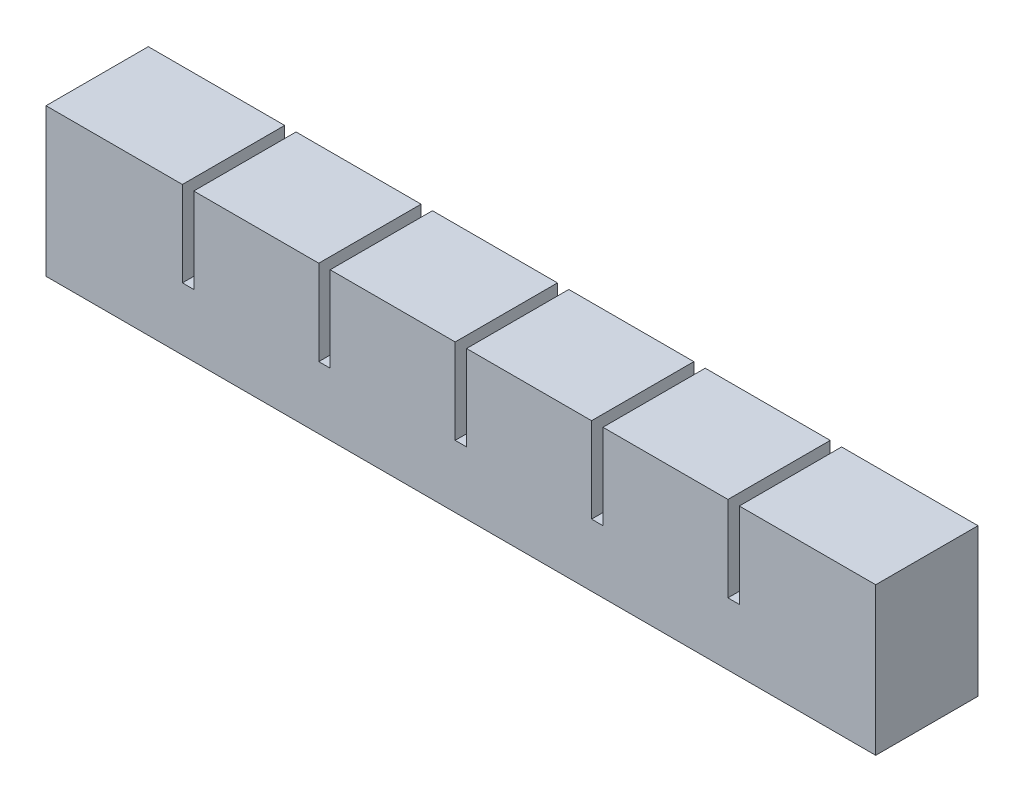
from build123d import *

# Parameters (mm, degrees)
SKETCH1_W           = 22
SKETCH1_H           = 20
BOSS_EXTRUDE1_DEPTH = 18
SKETCH2_W           = 12
SKETCH2_H           = 8
CUT_EXTRUDE1_DEPTH  = 15
SKETCH3_W           = 18
SKETCH3_H           = 5
BOSS_EXTRUDE2_DEPTH = 2
LPATTERN1_COUNT     = 6
LPATTERN1_PITCH     = 24
SKETCH4_W           = 18
SKETCH4_H           = 15
BOSS_EXTRUDE3_DEPTH = 2
SKETCH5_W           = 18
SKETCH5_H           = 20
BOSS_EXTRUDE4_DEPTH = 2
SKETCH6_W           = 132
SKETCH6_H           = 2
CUT_EXTRUDE2_DEPTH  = 2
SKETCH7_W           = 146
SKETCH7_H           = 18
BOSS_EXTRUDE5_DEPTH = 6


with BuildPart() as part:
    # Sketch1 → Boss-Extrude1 (new body)
    with BuildSketch(Plane.XY):
        with Locations((11, 10)):
            Rectangle(SKETCH1_W, SKETCH1_H)
    extrude(amount=BOSS_EXTRUDE1_DEPTH)

    # Sketch2 → Cut-Extrude1 (cut)
    with BuildSketch(Plane.XZ):
        with Locations((11, 9)):
            Rectangle(SKETCH2_W, SKETCH2_H)
    extrude(amount=-CUT_EXTRUDE1_DEPTH, mode=Mode.SUBTRACT)

    # Sketch3 → Boss-Extrude2 (add)
    with BuildSketch(Plane(origin=(22, 0, 0), x_dir=(0, 0, -1), z_dir=(1, 0, 0))):
        with Locations((-9, 2.5)):
            Rectangle(SKETCH3_W, SKETCH3_H)
    extrude(amount=BOSS_EXTRUDE2_DEPTH)


with BuildPart() as lpattern1_1:
    # LPattern1: pattern copy
    add(part.part.moved(Location(Vector(1, 0, 0) * (1 * LPATTERN1_PITCH))))


with BuildPart() as lpattern1_2:
    # LPattern1: pattern copy
    add(part.part.moved(Location(Vector(1, 0, 0) * (2 * LPATTERN1_PITCH))))


with BuildPart() as lpattern1_3:
    # LPattern1: pattern copy
    add(part.part.moved(Location(Vector(1, 0, 0) * (3 * LPATTERN1_PITCH))))


with BuildPart() as lpattern1_4:
    # LPattern1: pattern copy
    add(part.part.moved(Location(Vector(1, 0, 0) * (4 * LPATTERN1_PITCH))))


with BuildPart() as lpattern1_5:
    # LPattern1: pattern copy
    add(part.part.moved(Location(Vector(1, 0, 0) * (5 * LPATTERN1_PITCH))))


with BuildPart() as lpattern1_2_1:
    add(lpattern1_2.part)

    # Combine1: union part, LPattern1_3, LPattern1_4, LPattern1_5, LPattern1_1
    add(part.part)
    add(lpattern1_3.part)
    add(lpattern1_4.part)
    add(lpattern1_5.part)
    add(lpattern1_1.part)

    # Sketch4 → Boss-Extrude3 (add)
    with BuildSketch(Plane(origin=(142, 0, 0), x_dir=(0, 0, -1), z_dir=(1, 0, 0))):
        with Locations((-9, 12.5)):
            Rectangle(SKETCH4_W, SKETCH4_H)
    extrude(amount=BOSS_EXTRUDE3_DEPTH)

    # Sketch5 → Boss-Extrude4 (add)
    with BuildSketch(Plane.ZY):
        with Locations((9, 10)):
            Rectangle(SKETCH5_W, SKETCH5_H)
    extrude(amount=BOSS_EXTRUDE4_DEPTH)

    # Sketch6 → Cut-Extrude2 (cut)
    with BuildSketch(Plane(origin=(0, 0, 0), x_dir=(-1, 0, 0), z_dir=(0, -1, 0))):
        with Locations((-71, -9)):
            Rectangle(SKETCH6_W, SKETCH6_H)
    extrude(amount=-CUT_EXTRUDE2_DEPTH, mode=Mode.SUBTRACT)

    # Sketch7 → Boss-Extrude5 (add)
    with BuildSketch(Plane.XZ):
        with Locations((71, 9)):
            Rectangle(SKETCH7_W, SKETCH7_H)
    extrude(amount=BOSS_EXTRUDE5_DEPTH)


solid = lpattern1_2_1.part
